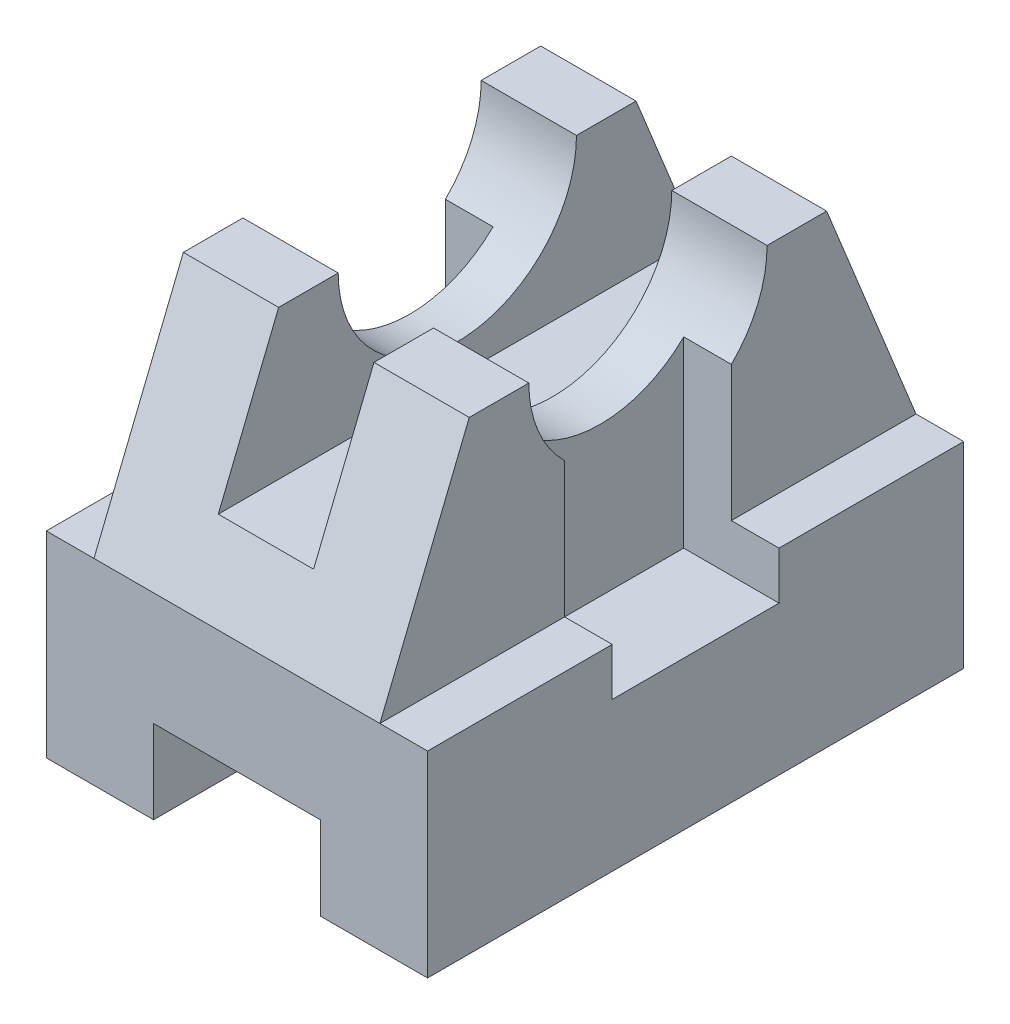
from build123d import *

# Parameters (mm, degrees)
SKETCH1_W           = 64
SKETCH1_H           = 90
BOSS_EXTRUDE1_DEPTH = 33
BOSS_EXTRUDE2_DEPTH = 24
SKETCH3_W           = 16
SKETCH3_H           = 92.520376572
CUT_EXTRUDE1_DEPTH  = 25
SKETCH6_W           = 16
SKETCH6_H           = 28
CUT_EXTRUDE3_DEPTH  = 45
SKETCH7_W           = 28
SKETCH7_H           = 14
CUT_EXTRUDE4_DEPTH  = 91


with BuildPart() as part:
    # Sketch1 → Boss-Extrude1 (new body)
    with BuildSketch(Plane(origin=(0, 0, 0), x_dir=(1, 0, 0), z_dir=(0, 1, 0))):
        Rectangle(SKETCH1_W, SKETCH1_H)
    extrude(amount=BOSS_EXTRUDE1_DEPTH)

    # Sketch2 → Boss-Extrude2 (add, symmetric)
    with BuildSketch(Plane(origin=(0, 0, 0), x_dir=(0, 0, -1), z_dir=(1, 0, 0))):
        with BuildLine():
            Line((45, 33), (-45, 33))
            Line((-45, 33), (-30, 70))
            Line((-30, 70), (-20, 70))
            ThreePointArc((-20, 70), (0, 50), (20, 70))
            Line((20, 70), (30, 70))
            Line((30, 70), (45, 33))
        make_face()
    extrude(amount=BOSS_EXTRUDE2_DEPTH, both=True)

    # Sketch3 → Cut-Extrude1 (cut)
    with BuildSketch(Plane(origin=(0, 70, 0), x_dir=(1, 0, 0), z_dir=(0, 1, 0))):
        Rectangle(SKETCH3_W, SKETCH3_H)
    extrude(amount=-CUT_EXTRUDE1_DEPTH, mode=Mode.SUBTRACT)

    # Sketch6 → Cut-Extrude3 (cut)
    with BuildSketch(Plane(origin=(0, 70, 0), x_dir=(1, 0, 0), z_dir=(0, 1, 0))):
        with Locations((24, 0)):
            Rectangle(SKETCH6_W, SKETCH6_H)
        with Locations((-24, 0)):
            Rectangle(SKETCH6_W, SKETCH6_H)
    extrude(amount=-CUT_EXTRUDE3_DEPTH, mode=Mode.SUBTRACT)

    # Sketch7 → Cut-Extrude4 (cut, through all)
    with BuildSketch(Plane.XY.offset(45)):
        with Locations((0, 7)):
            Rectangle(SKETCH7_W, SKETCH7_H)
    extrude(amount=-CUT_EXTRUDE4_DEPTH, mode=Mode.SUBTRACT)


solid = part.part
